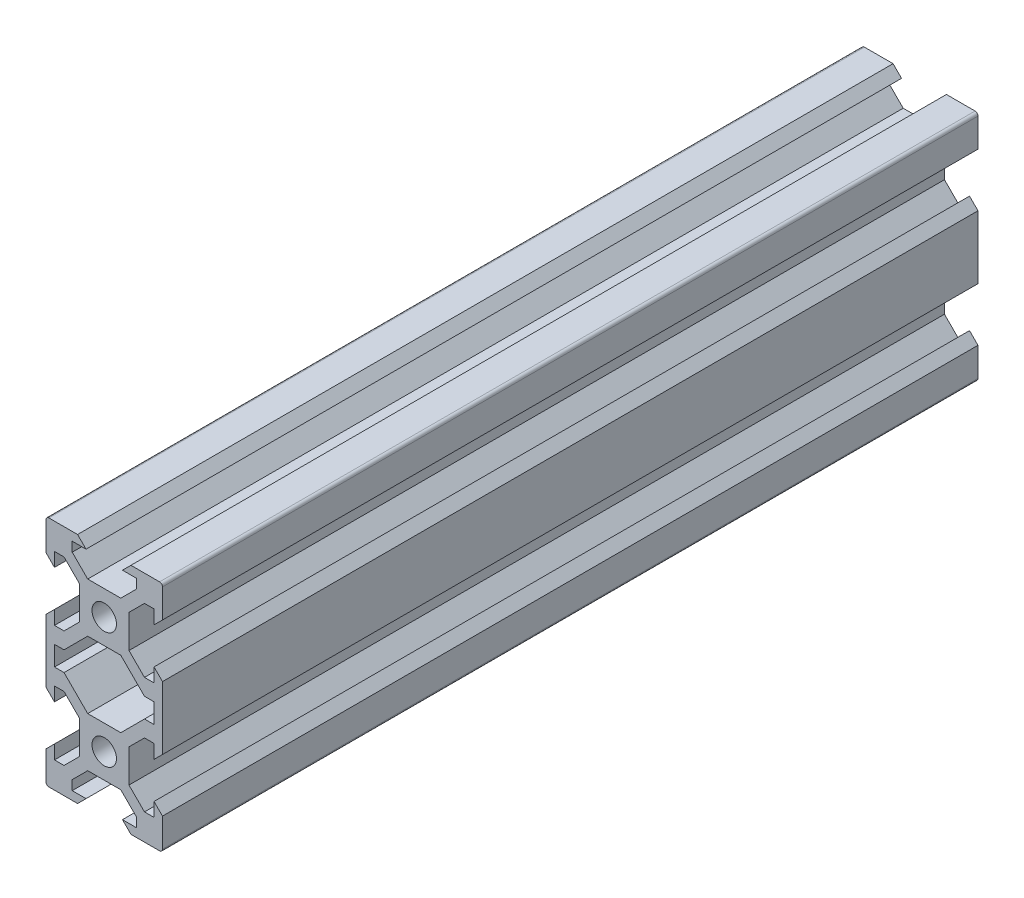
from build123d import *

# Parameters (mm, degrees)
SKETCH2_R           = 2.1
BOSS_EXTRUDE1_DEPTH = 140


with BuildPart() as part:
    # Sketch2 → Boss-Extrude1 (new body)
    with BuildSketch(Plane.XY):
        with BuildLine():
            Line((-10, 15.42), (-10, 10))
            Line((-10, 10), (-8.545, 10))
            Line((-8.545, 10), (-8.545, 11.69))
            Line((-8.545, 11.69), (-6.905, 11.69))
            Line((-6.905, 11.69), (-2.84, 15.755))
            Line((-2.84, 15.755), (2.84, 15.755))
            Line((2.84, 15.755), (6.905, 11.69))
            Line((6.905, 11.69), (8.545, 11.69))
            Line((8.545, 11.69), (8.545, 10))
            Line((8.545, 10), (10, 10))
            Line((10, 10), (10, 15.42))
            Line((10, 15.42), (8.545, 16.875))
            Line((8.545, 16.875), (8.545, 14.5))
            Line((8.545, 14.5), (6.905, 14.5))
            Line((6.905, 14.5), (4.245, 17.16))
            Line((4.245, 17.16), (4.245, 22.84))
            Line((4.245, 22.84), (6.905, 25.5))
            Line((6.905, 25.5), (8.545, 25.5))
            Line((8.545, 25.5), (8.545, 23.125))
            Line((8.545, 23.125), (10, 24.58))
            Line((10, 24.58), (10, 29.5))
            ThreePointArc((10, 29.5), (9.853553391, 29.853553391), (9.5, 30))
            Line((9.5, 30), (4.58, 30))
            Line((4.58, 30), (3.125, 28.545))
            Line((3.125, 28.545), (5.5, 28.545))
            Line((5.5, 28.545), (5.5, 26.905))
            Line((5.5, 26.905), (2.84, 24.245))
            Line((2.84, 24.245), (-2.84, 24.245))
            Line((-2.84, 24.245), (-5.5, 26.905))
            Line((-5.5, 26.905), (-5.5, 28.545))
            Line((-5.5, 28.545), (-3.125, 28.545))
            Line((-3.125, 28.545), (-4.58, 30))
            Line((-4.58, 30), (-9.5, 30))
            ThreePointArc((-9.5, 30), (-9.853553391, 29.853553391), (-10, 29.5))
            Line((-10, 29.5), (-10, 24.58))
            Line((-10, 24.58), (-8.545, 23.125))
            Line((-8.545, 23.125), (-8.545, 25.5))
            Line((-8.545, 25.5), (-6.905, 25.5))
            Line((-6.905, 25.5), (-4.245, 22.84))
            Line((-4.245, 22.84), (-4.245, 17.16))
            Line((-4.245, 17.16), (-6.905, 14.5))
            Line((-6.905, 14.5), (-8.545, 14.5))
            Line((-8.545, 14.5), (-8.545, 16.875))
            Line((-8.545, 16.875), (-10, 15.42))
        make_face()
        with Locations((0, 20)):
            Circle(SKETCH2_R, mode=Mode.SUBTRACT)
        with BuildLine():
            Line((-9.5, -10), (-4.58, -10))
            Line((-4.58, -10), (-3.125, -8.545))
            Line((-3.125, -8.545), (-5.5, -8.545))
            Line((-5.5, -8.545), (-5.5, -6.905))
            Line((-5.5, -6.905), (-2.84, -4.245))
            Line((-2.84, -4.245), (2.84, -4.245))
            Line((2.84, -4.245), (5.5, -6.905))
            Line((5.5, -6.905), (5.5, -8.545))
            Line((5.5, -8.545), (3.125, -8.545))
            Line((3.125, -8.545), (4.58, -10))
            Line((4.58, -10), (9.5, -10))
            ThreePointArc((9.5, -10), (9.853553391, -9.853553391), (10, -9.5))
            Line((10, -9.5), (10, -4.58))
            Line((10, -4.58), (8.545, -3.125))
            Line((8.545, -3.125), (8.545, -5.5))
            Line((8.545, -5.5), (6.905, -5.5))
            Line((6.905, -5.5), (4.245, -2.84))
            Line((4.245, -2.84), (4.245, 2.84))
            Line((4.245, 2.84), (6.905, 5.5))
            Line((6.905, 5.5), (8.545, 5.5))
            Line((8.545, 5.5), (8.545, 3.125))
            Line((8.545, 3.125), (10, 4.58))
            Line((10, 4.58), (10, 10))
            Line((10, 10), (8.545, 10))
            Line((8.545, 10), (8.545, 8.31))
            Line((8.545, 8.31), (6.905, 8.31))
            Line((6.905, 8.31), (2.84, 4.245))
            Line((2.84, 4.245), (-2.84, 4.245))
            Line((-2.84, 4.245), (-6.905, 8.31))
            Line((-6.905, 8.31), (-8.545, 8.31))
            Line((-8.545, 8.31), (-8.545, 10))
            Line((-8.545, 10), (-10, 10))
            Line((-10, 10), (-10, 4.58))
            Line((-10, 4.58), (-8.545, 3.125))
            Line((-8.545, 3.125), (-8.545, 5.5))
            Line((-8.545, 5.5), (-6.905, 5.5))
            Line((-6.905, 5.5), (-4.245, 2.84))
            Line((-4.245, 2.84), (-4.245, -2.84))
            Line((-4.245, -2.84), (-6.905, -5.5))
            Line((-6.905, -5.5), (-8.545, -5.5))
            Line((-8.545, -5.5), (-8.545, -3.125))
            Line((-8.545, -3.125), (-10, -4.58))
            Line((-10, -4.58), (-10, -9.5))
            ThreePointArc((-10, -9.5), (-9.853553391, -9.853553391), (-9.5, -10))
        make_face()
        Circle(SKETCH2_R, mode=Mode.SUBTRACT)
    extrude(amount=BOSS_EXTRUDE1_DEPTH)


solid = part.part
